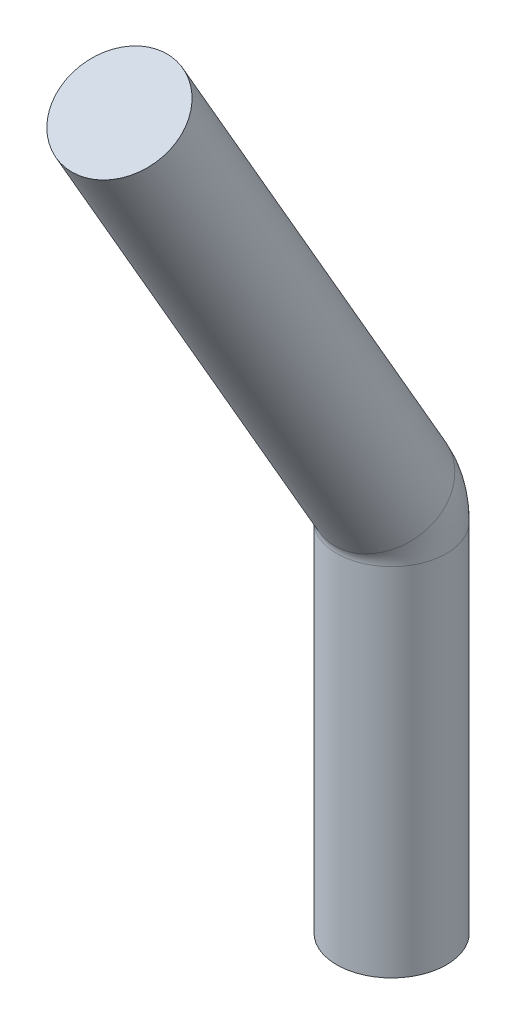
from build123d import *

# Parameters (mm, degrees)
SKETCH23_R          = 0.47
SKETCH25_R          = 0.47
BOSS_EXTRUDE2_DEPTH = 2.55


with BuildPart() as part:
    # Sweep4: sweep along a path in Sketch24
    with BuildLine(Plane(origin=(0, 0, 0), x_dir=(0, 0, -1), z_dir=(1, 0, 0))) as sweep4_path:
        Line((0, 0), (0, 0.5))
        ThreePointArc((0, 0.5), (-0.020444504, 0.655291427), (-0.080384758, 0.8))
        Line((-0.080384758, 0.8), (-2.330384758, 4.697114317))
    # Sketch23 → Sweep4 (sweep)
    with BuildSketch(Plane(origin=(0, 0, 0), x_dir=(1, 0, 0), z_dir=(0, 1, 0))):
        Circle(SKETCH23_R)
    sweep(path=sweep4_path.line)

    # Sketch25 → Boss-Extrude2 (add)
    with BuildSketch(Plane(origin=(0, 0, 0), x_dir=(-1, 0, 0), z_dir=(0, -1, 0))):
        Circle(SKETCH25_R)
    extrude(amount=BOSS_EXTRUDE2_DEPTH)


solid = part.part
